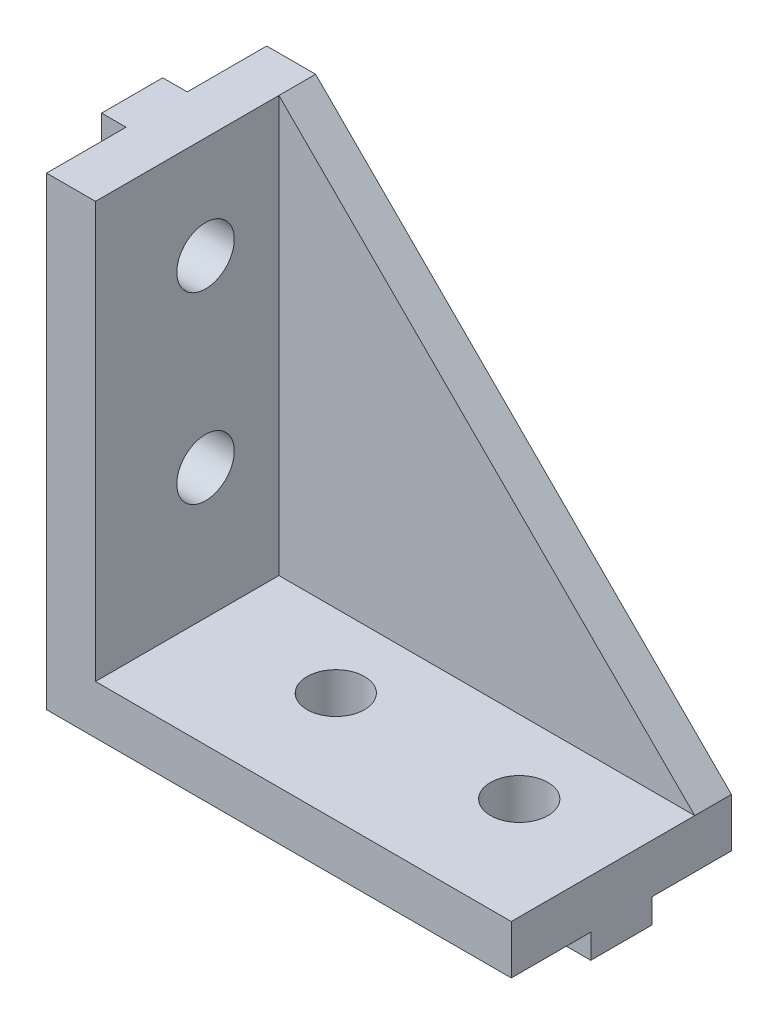
from build123d import *

# Parameters (mm, degrees)
EXTRUDE_1_DEPTH     = 9
SKETCH_3_R          = 2.35
CUT_EXTRUDE_1_DEPTH = 5
SKETCH_4_W          = 2
SKETCH_4_H          = 5
EXTRUDE_3_DEPTH     = 2
EXTRUDE_4_DEPTH     = 3


with BuildPart() as part:
    # Эскиз1 → Бобышка-Вытянуть1 (new body, symmetric)
    with BuildSketch(Plane.XY):
        Polygon((0, 38), (0, 0), (38, 0), (38, 4), (4, 4), (4, 38), align=None)
    extrude(amount=EXTRUDE_1_DEPTH, both=True)

    # Эскиз3 → Вырез-Вытянуть1 (cut, through all)
    with BuildSketch(Plane(origin=(0, 4, 0), x_dir=(1, 0, 0), z_dir=(0, 1, 0))):
        with Locations(Location((14.65, 0, 0), (0, 0, 270))):  # turned: the seam where the file's is
            Circle(SKETCH_3_R)
        with Locations(Location((29.65, 0, 0), (0, 0, 270))):  # turned: the seam where the file's is
            Circle(SKETCH_3_R)
    cut_extrude_1 = extrude(amount=-CUT_EXTRUDE_1_DEPTH, mode=Mode.SUBTRACT)

    # Эскиз4 → Бобышка-Вытянуть3 (add)
    with BuildSketch(Plane.XZ):
        with Locations((1, 0)):
            Rectangle(SKETCH_4_W, SKETCH_4_H)
        with Locations((37, 0)):
            Rectangle(SKETCH_4_W, SKETCH_4_H)
    extrude_3 = extrude(amount=EXTRUDE_3_DEPTH)

    # Зеркальное отражение3: Вырез-Вытянуть1, Бобышка-Вытянуть3 across plane
    add(cut_extrude_1.mirror(Plane(origin=(0, 0, 0), x_dir=(0, 0, 1), z_dir=(-0.707106781, 0.707106781, 0))), mode=Mode.SUBTRACT)
    add(extrude_3.mirror(Plane(origin=(0, 0, 0), x_dir=(0, 0, 1), z_dir=(-0.707106781, 0.707106781, 0))))

    # Эскиз2 → Бобышка-Вытянуть4 (add)
    with BuildSketch(Plane.XY.offset(-9)):
        Polygon((4, 38), (38, 4), (4, 4), align=None)
    extrude(amount=EXTRUDE_4_DEPTH)


solid = part.part
